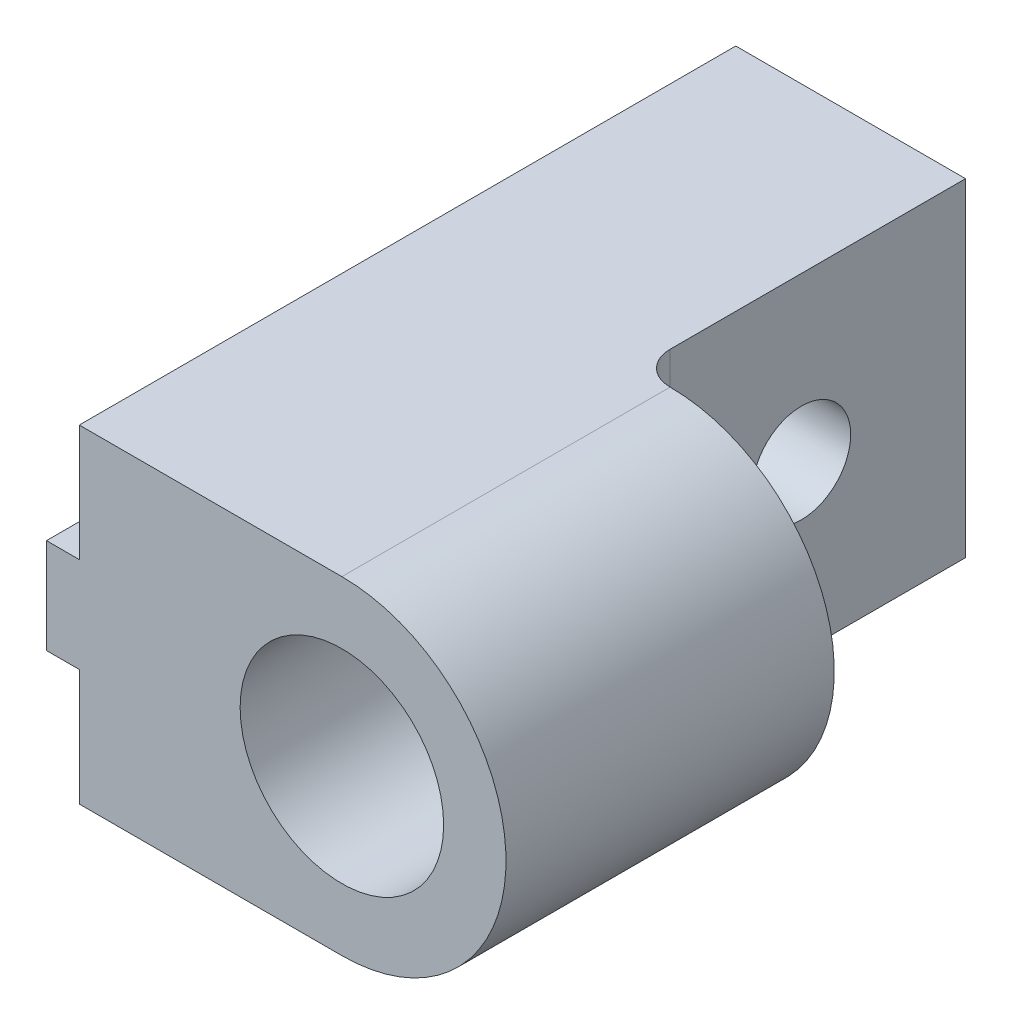
from build123d import *

# Parameters (mm, degrees)
MAIN_DEPTH                     = 20
SKETCH2_R                      = 3.1
SHAFTHOLE_DEPTH                = 5
SKETCH3_W                      = 10
SKETCH3_H                      = 10
MAKERBEAMRECTANGULARHOLE_DEPTH = 7
SKETCH4_R                      = 1.5
MAKERBEAMHOLE_DEPTH            = 9
FILLET1_R                      = 1


with BuildPart() as part:
    # Sketch1 → Main (new body)
    with BuildSketch(Plane.XY):
        with BuildLine():
            Line((-8, 5), (-8, 1.45))
            Line((-8, 1.45), (-9, 1.45))
            Line((-9, 1.45), (-9, -1.45))
            Line((-9, -1.45), (-8, -1.45))
            Line((-8, -1.45), (-8, -5))
            Line((-8, -5), (0, -5))
            ThreePointArc((0, -5), (5, 0), (0, 5))
            Line((0, 5), (-8, 5))
        make_face()
    extrude(amount=MAIN_DEPTH)

    # Sketch2 → ShaftHole (cut)
    with BuildSketch(Plane.XY.offset(20)):
        Circle(SKETCH2_R)
    extrude(amount=-SHAFTHOLE_DEPTH, mode=Mode.SUBTRACT)

    # Sketch3 → MakerBeamRectangularHole (cut, through all)
    with BuildSketch(Plane(origin=(-1, 0, 0), x_dir=(0, 0, -1), z_dir=(1, 0, 0))):
        with Locations((-5, 0)):
            Rectangle(SKETCH3_W, SKETCH3_H)
    extrude(amount=MAKERBEAMRECTANGULARHOLE_DEPTH, mode=Mode.SUBTRACT)

    # Sketch4 → MakerBeamHole (cut, through all)
    with BuildSketch(Plane(origin=(-1, 0, 0), x_dir=(0, 0, -1), z_dir=(1, 0, 0))):
        with Locations((-5, 0)):
            Circle(SKETCH4_R)
    extrude(amount=-MAKERBEAMHOLE_DEPTH, mode=Mode.SUBTRACT)

    # Fillet1
    fillet1_edges = [part.edges().sort_by_distance(p)[0] for p in [
        (-1, 0, 10),
    ]]
    fillet(fillet1_edges, radius=FILLET1_R)


solid = part.part
